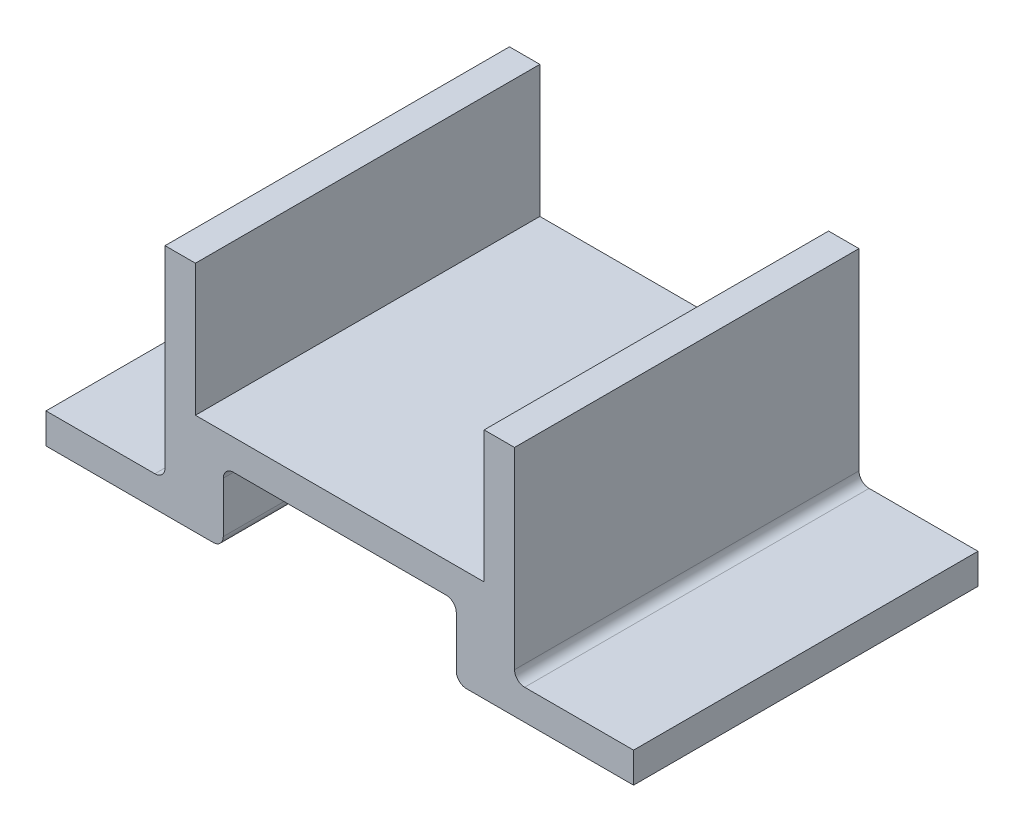
from build123d import *

# Parameters (mm, degrees)
SKETCH1_W           = 58
SKETCH1_H           = 34
BOSS_EXTRUDE1_DEPTH = 10
SKETCH3_W           = 23
SKETCH3_H           = 7
CUT_EXTRUDE1_DEPTH  = 34
SKETCH4_W           = 11.75
SKETCH4_H           = 7
CUT_EXTRUDE2_DEPTH  = 34
SKETCH6_W           = 3
SKETCH6_H           = 34
BOSS_EXTRUDE2_DEPTH = 13
FILLET1_R           = 1


with BuildPart() as part:
    # Sketch1 → Boss-Extrude1 (new body)
    with BuildSketch(Plane(origin=(0, 0, 0), x_dir=(1, 0, 0), z_dir=(0, 1, 0))):
        Rectangle(SKETCH1_W, SKETCH1_H)
    extrude(amount=BOSS_EXTRUDE1_DEPTH)

    # Sketch3 → Cut-Extrude1 (cut)
    with BuildSketch(Plane.XY.offset(17)):
        with Locations((0, 3.5)):
            Rectangle(SKETCH3_W, SKETCH3_H)
    extrude(amount=-CUT_EXTRUDE1_DEPTH, mode=Mode.SUBTRACT)

    # Sketch4 → Cut-Extrude2 (cut)
    with BuildSketch(Plane.XY.offset(17)):
        with Locations((23.125, 6.5)):
            Rectangle(SKETCH4_W, SKETCH4_H)
    cut_extrude2 = extrude(amount=-CUT_EXTRUDE2_DEPTH, mode=Mode.SUBTRACT)

    # Mirror1: Cut-Extrude2 across plane
    add(cut_extrude2.mirror(Plane(origin=(0, 0, 0), x_dir=(0, 0, 1), z_dir=(1, 0, 0))), mode=Mode.SUBTRACT)

    # Sketch6 → Boss-Extrude2 (add)
    with BuildSketch(Plane(origin=(0, 10, 0), x_dir=(1, 0, 0), z_dir=(0, 1, 0))):
        with Locations((15.75, 0)):
            Rectangle(SKETCH6_W, SKETCH6_H)
    boss_extrude2 = extrude(amount=BOSS_EXTRUDE2_DEPTH)

    # Mirror2: Boss-Extrude2 across plane
    add(boss_extrude2.mirror(Plane(origin=(0, 0, 0), x_dir=(0, 0, 1), z_dir=(1, 0, 0))))

    # Fillet1
    fillet1_edges = [part.edges().sort_by_distance(p)[0] for p in [
        (-11.5, 0, 0),
        (-11.5, 7, 0),
        (11.5, 7, 0),
        (11.5, 0, 0),
        (17.25, 3, 0),
        (-17.25, 3, 0),
    ]]
    fillet(fillet1_edges, radius=FILLET1_R)


solid = part.part
